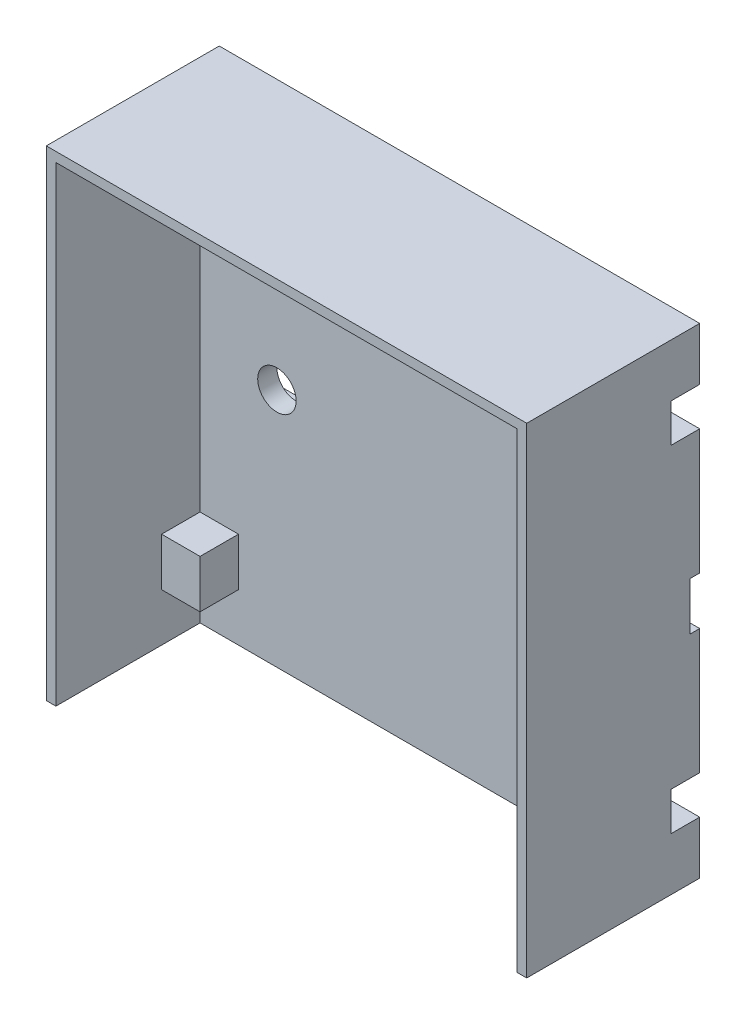
from build123d import *

# Parameters (mm, degrees)
SKICA1_W                  = 50
SKICA1_H                  = 50
P_IDAT_VYSUNUT_M2_DEPTH   = 3
SKICA5_W                  = 50
SKICA5_H                  = 5
ODEBRAT_VYSUNUT_M3_DEPTH  = 1
P_IDAT_VYSUNUT_M9_DEPTH   = 15
SKICA17_R                 = 2
ODEBRAT_VYSUNUT_M8_DEPTH  = 4
SKICA18_W                 = 5
SKICA18_H                 = 5
P_IDAT_VYSUNUT_M10_DEPTH  = 7
SKICA19_W                 = 4
SKICA19_H                 = 4
ODEBRAT_VYSUNUT_M9_DEPTH  = 3
SKICA20_R                 = 1.25
ODEBRAT_VYSUNUT_M10_DEPTH = 3


with BuildPart() as part:
    # Skica1 → Přidat vysunutím2 (new body)
    with BuildSketch(Plane.XY):
        Rectangle(SKICA1_W, SKICA1_H)
    extrude(amount=P_IDAT_VYSUNUT_M2_DEPTH)

    # Skica5 → Odebrat vysunutím3 (cut)
    with BuildSketch(Plane(origin=(0, 0, 0), x_dir=(-1, 0, 0), z_dir=(0, 0, -1))):
        Rectangle(SKICA5_W, SKICA5_H)
    extrude(amount=-ODEBRAT_VYSUNUT_M3_DEPTH, mode=Mode.SUBTRACT)

    # Skica14 → Přidat vysunutím9 (add)
    with BuildSketch(Plane.XY.offset(3)):
        Polygon((25, 25), (-25, 25), (-25, -25), (-24, -25), (-24, 24), (24, 24), (24, -25), (25, -25), align=None)
    extrude(amount=P_IDAT_VYSUNUT_M9_DEPTH)

    # Skica17 → Odebrat vysunutím8 (cut)
    with BuildSketch(Plane(origin=(0, 0, 1), x_dir=(-1, 0, 0), z_dir=(0, 0, -1))):
        with Locations((-16, 0)):
            Circle(SKICA17_R)
        with Locations((16, 0)):
            Circle(SKICA17_R)
    extrude(amount=-ODEBRAT_VYSUNUT_M8_DEPTH, mode=Mode.SUBTRACT)

    # Skica18 → Přidat vysunutím10 (add)
    with BuildSketch(Plane(origin=(0, 0, 0), x_dir=(-1, 0, 0), z_dir=(0, 0, -1))):
        with Locations((-22.5, 17.5)):
            Rectangle(SKICA18_W, SKICA18_H)
        with Locations((-22.5, -17.5)):
            Rectangle(SKICA18_W, SKICA18_H)
        with Locations((22.5, -17.5)):
            Rectangle(SKICA18_W, SKICA18_H)
        with Locations((22.5, 17.5)):
            Rectangle(SKICA18_W, SKICA18_H)
    extrude(amount=-P_IDAT_VYSUNUT_M10_DEPTH)

    # Skica19 → Odebrat vysunutím9 (cut)
    with BuildSketch(Plane(origin=(0, 0, 0), x_dir=(-1, 0, 0), z_dir=(0, 0, -1))):
        with Locations((-23, 17.5)):
            Rectangle(SKICA19_W, SKICA19_H)
        with Locations((-23, -17.5)):
            Rectangle(SKICA19_W, SKICA19_H)
        with Locations((23, -17.5)):
            Rectangle(SKICA19_W, SKICA19_H)
        with Locations((23, 17.5)):
            Rectangle(SKICA19_W, SKICA19_H)
    extrude(amount=-ODEBRAT_VYSUNUT_M9_DEPTH, mode=Mode.SUBTRACT)

    # Skica20 → Odebrat vysunutím10 (cut)
    with BuildSketch(Plane(origin=(0, 0, 3), x_dir=(-1, 0, 0), z_dir=(0, 0, -1))):
        with Locations((-22.75, 17.5)):
            Circle(SKICA20_R)
        with Locations((22.75, 17.5)):
            Circle(SKICA20_R)
        with Locations((22.75, -17.5)):
            Circle(SKICA20_R)
        with Locations((-22.75, -17.5)):
            Circle(SKICA20_R)
    extrude(amount=-ODEBRAT_VYSUNUT_M10_DEPTH, mode=Mode.SUBTRACT)


solid = part.part
